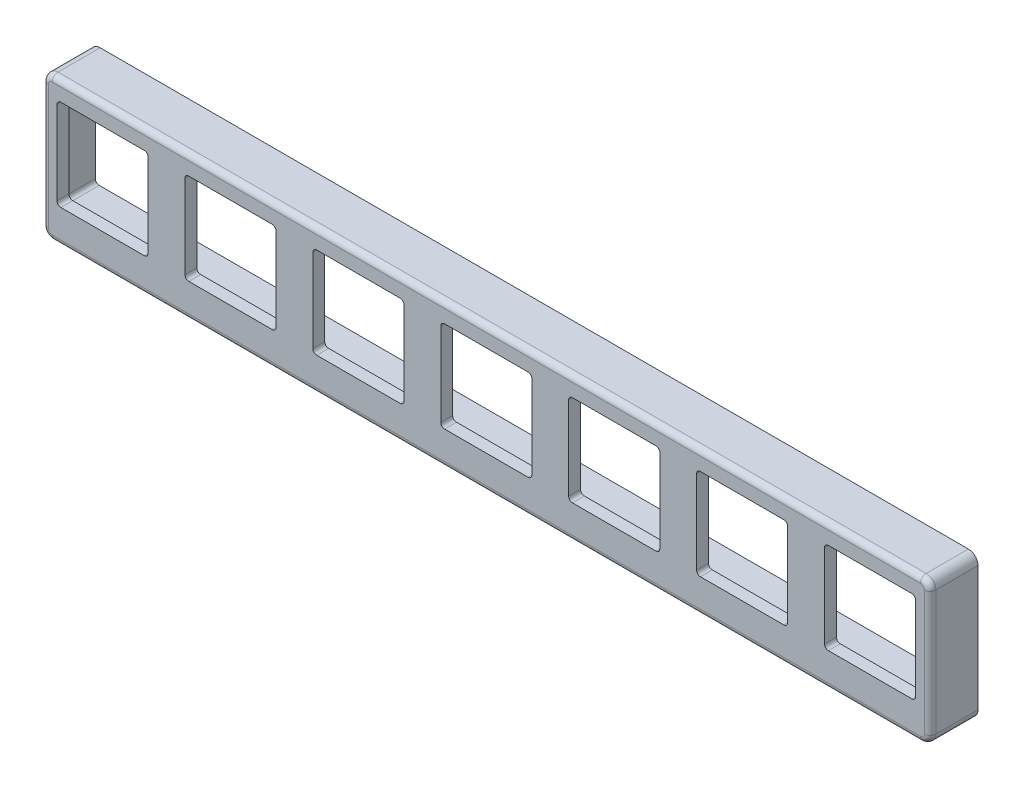
from build123d import *

# Parameters (mm, degrees)
SKETCH1_W             = 117.475
SKETCH1_H             = 19.05
BOSS_EXTRUDE1_DEPTH   = 9.525
BOSS_EXTRUDE2_DEPTH   = 3.175
F_6_CLEARANCE_HOLE1_D = 4.3053
SKETCH5_W             = 12.065
SKETCH5_H             = 12.065
CUT_EXTRUDE1_DEPTH    = 10.525
SKETCH7_W             = 116.205
SKETCH7_H             = 14.605
CUT_EXTRUDE2_DEPTH    = 7.9502
SKETCH8_W             = 117.475
SKETCH8_H             = 28.575
CUT_EXTRUDE3_DEPTH    = 3.175
FILLET2_R             = 1.27
FILLET3_R             = 0.762
FILLET4_R             = 0.508
FILLET5_R             = 0.508


with BuildPart() as part:
    # Sketch1 → Boss-Extrude1 (new body)
    with BuildSketch(Plane.XY):
        with Locations((0, -57.6104797)):
            Rectangle(SKETCH1_W, SKETCH1_H)
    extrude(amount=BOSS_EXTRUDE1_DEPTH)

    # Sketch2 → Boss-Extrude2 (add)
    with BuildSketch(Plane.XY):
        with BuildLine():
            Line((35.56, -48.0854797), (58.7375, -48.0854797))
            Line((58.7375, -48.0854797), (44.939976119, -39.26086832))
            ThreePointArc((44.939976119, -39.26086832), (40.410479427, -39.106525106), (38.1, -43.0054797))
            Line((38.1, -43.0054797), (38.1, -45.5454797))
            ThreePointArc((38.1, -45.5454797), (37.356051224, -47.341530924), (35.56, -48.0854797))
        make_face()
        with BuildLine():
            Line((-38.1, -45.5454797), (-38.1, -43.0054797))
            ThreePointArc((-38.1, -43.0054797), (-40.410479427, -39.106525106), (-44.939976119, -39.26086832))
            Line((-44.939976119, -39.26086832), (-58.7375, -48.0854797))
            Line((-58.7375, -48.0854797), (-35.56, -48.0854797))
            ThreePointArc((-35.56, -48.0854797), (-37.356051224, -47.341530924), (-38.1, -45.5454797))
        make_face()
    extrude(amount=BOSS_EXTRUDE2_DEPTH)

    # #6 Clearance Hole1 (through all)
    with Locations(Plane.XY.offset(3.175)):
        with Locations((42.545, -43.0054797), (-42.545, -43.0054797)):
            Hole(F_6_CLEARANCE_HOLE1_D / 2)

    # Sketch5 → Cut-Extrude1 (cut, through all)
    with BuildSketch(Plane.XY.offset(9.525)):
        with Locations((50.8, -56.6198797)):
            Rectangle(SKETCH5_W, SKETCH5_H)
        with Locations((33.866666667, -56.6198797)):
            Rectangle(SKETCH5_W, SKETCH5_H)
        with Locations((16.933333333, -56.6198797)):
            Rectangle(SKETCH5_W, SKETCH5_H)
        with Locations((0, -56.6198797)):
            Rectangle(SKETCH5_W, SKETCH5_H)
        with Locations((-16.933333333, -56.6198797)):
            Rectangle(SKETCH5_W, SKETCH5_H)
        with Locations((-33.866666667, -56.6198797)):
            Rectangle(SKETCH5_W, SKETCH5_H)
        with Locations((-50.8, -56.6198797)):
            Rectangle(SKETCH5_W, SKETCH5_H)
    extrude(amount=-CUT_EXTRUDE1_DEPTH, mode=Mode.SUBTRACT)

    # Sketch7 → Cut-Extrude2 (cut)
    with BuildSketch(Plane(origin=(0, 0, 0), x_dir=(-1, 0, 0), z_dir=(0, 0, -1))):
        with Locations((0, -56.6198797)):
            Rectangle(SKETCH7_W, SKETCH7_H)
    extrude(amount=-CUT_EXTRUDE2_DEPTH, mode=Mode.SUBTRACT)

    # Sketch8 → Cut-Extrude3 (cut)
    with BuildSketch(Plane(origin=(0, 0, 0), x_dir=(-1, 0, 0), z_dir=(0, 0, -1))):
        with Locations((0, -52.8479797)):
            Rectangle(SKETCH8_W, SKETCH8_H)
    extrude(amount=-CUT_EXTRUDE3_DEPTH, mode=Mode.SUBTRACT)

    # Fillet2
    fillet2_edges = [part.edges().sort_by_distance(p)[0] for p in [
        (58.7375, -67.1354797, 6.35),
        (58.7375, -48.0854797, 6.35),
        (-58.7375, -48.0854797, 6.35),
        (-58.7375, -67.1354797, 6.35),
    ]]
    fillet(fillet2_edges, radius=FILLET2_R)

    # Fillet3
    fillet3_edges = [part.edges().sort_by_distance(p)[0] for p in [
        (-58.7375, -57.6104797, 9.525),
        (0, -48.0854797, 9.525),
        (0, -67.1354797, 9.525),
        (58.7375, -57.6104797, 9.525),
        (58.365525612, -66.763505312, 9.525),
        (58.365525612, -48.457454088, 9.525),
        (-58.365525612, -66.763505312, 9.525),
        (-58.365525612, -48.457454088, 9.525),
    ]]
    fillet(fillet3_edges, radius=FILLET3_R)

    # Fillet4
    fillet4_edges = [part.edges().sort_by_distance(p)[0] for p in [
        (0, -63.9223797, 7.9502),
        (-58.1025, -63.9223797, 5.5626),
        (-58.1025, -56.6198797, 7.9502),
        (-58.1025, -49.3173797, 5.5626),
        (0, -49.3173797, 7.9502),
        (58.1025, -49.3173797, 5.5626),
        (58.1025, -56.6198797, 7.9502),
        (58.1025, -63.9223797, 5.5626),
    ]]
    fillet(fillet4_edges, radius=FILLET4_R)

    # Fillet5
    fillet5_edges = [part.edges().sort_by_distance(p)[0] for p in [
        (-56.8325, -50.5873797, 8.7376),
        (-44.7675, -50.5873797, 8.7376),
        (-56.8325, -62.6523797, 8.7376),
        (-44.7675, -62.6523797, 8.7376),
        (-39.899166667, -50.5873797, 8.7376),
        (-27.834166667, -50.5873797, 8.7376),
        (-39.899166667, -62.6523797, 8.7376),
        (-27.834166667, -62.6523797, 8.7376),
        (-22.965833333, -50.5873797, 8.7376),
        (-10.900833333, -50.5873797, 8.7376),
        (-22.965833333, -62.6523797, 8.7376),
        (-10.900833333, -62.6523797, 8.7376),
        (-6.0325, -50.5873797, 8.7376),
        (6.0325, -50.5873797, 8.7376),
        (-6.0325, -62.6523797, 8.7376),
        (6.0325, -62.6523797, 8.7376),
        (10.900833333, -62.6523797, 8.7376),
        (10.900833333, -50.5873797, 8.7376),
        (22.965833333, -62.6523797, 8.7376),
        (22.965833333, -50.5873797, 8.7376),
        (39.899166667, -50.5873797, 8.7376),
        (39.899166667, -62.6523797, 8.7376),
        (27.834166667, -50.5873797, 8.7376),
        (27.834166667, -62.6523797, 8.7376),
        (44.7675, -50.5873797, 8.7376),
        (56.8325, -50.5873797, 8.7376),
        (44.7675, -62.6523797, 8.7376),
        (56.8325, -62.6523797, 8.7376),
    ]]
    fillet(fillet5_edges, radius=FILLET5_R)


solid = part.part
